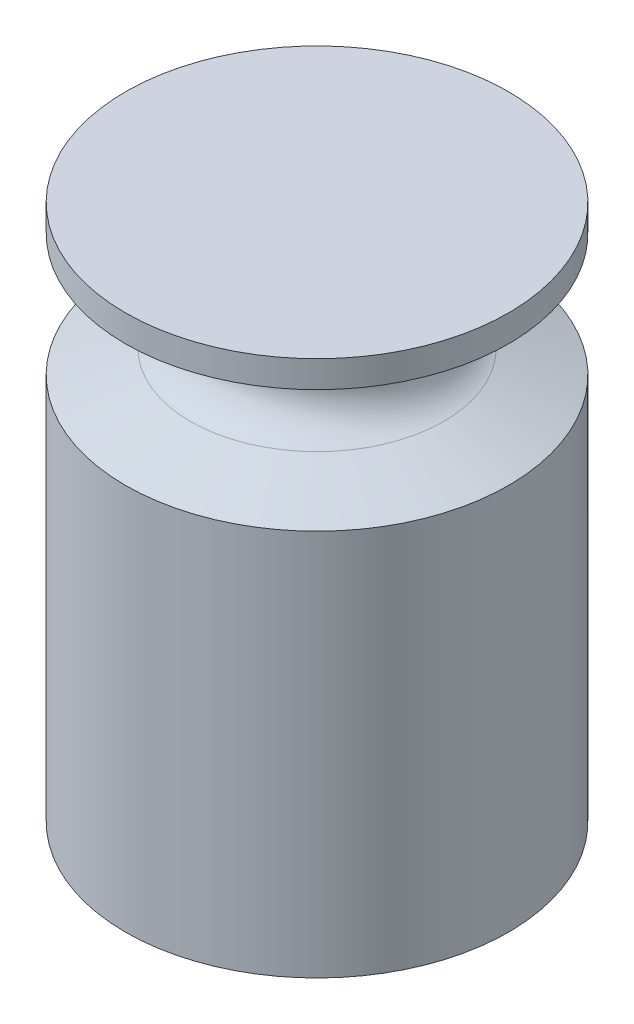
from build123d import *

# Parameters (mm, degrees)
SKETCH1_R           = 25
BOSS_EXTRUDE1_DEPTH = 70


with BuildPart() as part:
    # Sketch1 → Boss-Extrude1 (new body)
    with BuildSketch(Plane(origin=(0, 0, 0), x_dir=(1, 0, 0), z_dir=(0, 1, 0))):
        Circle(SKETCH1_R)
    extrude(amount=BOSS_EXTRUDE1_DEPTH)

    # Sketch2 → Cut-Revolve1 (revolve, cut)
    with BuildSketch(Plane(origin=(0, 0, 0), x_dir=(0, 0, -1), z_dir=(1, 0, 0))):
        with BuildLine():
            Line((25, 50.5), (16.532991719, 53.5))
            ThreePointArc((16.532991719, 53.5), (13.972369333, 55.438871512), (13, 58.5))
            ThreePointArc((13, 58.5), (13.972369333, 61.561128488), (16.532991719, 63.5))
            Line((16.532991719, 63.5), (25, 66.5))
            Line((25, 66.5), (25, 50.5))
        make_face()
    revolve(axis=Axis((0, 73.5, 0), (0, -1, 0)), mode=Mode.SUBTRACT)


solid = part.part
